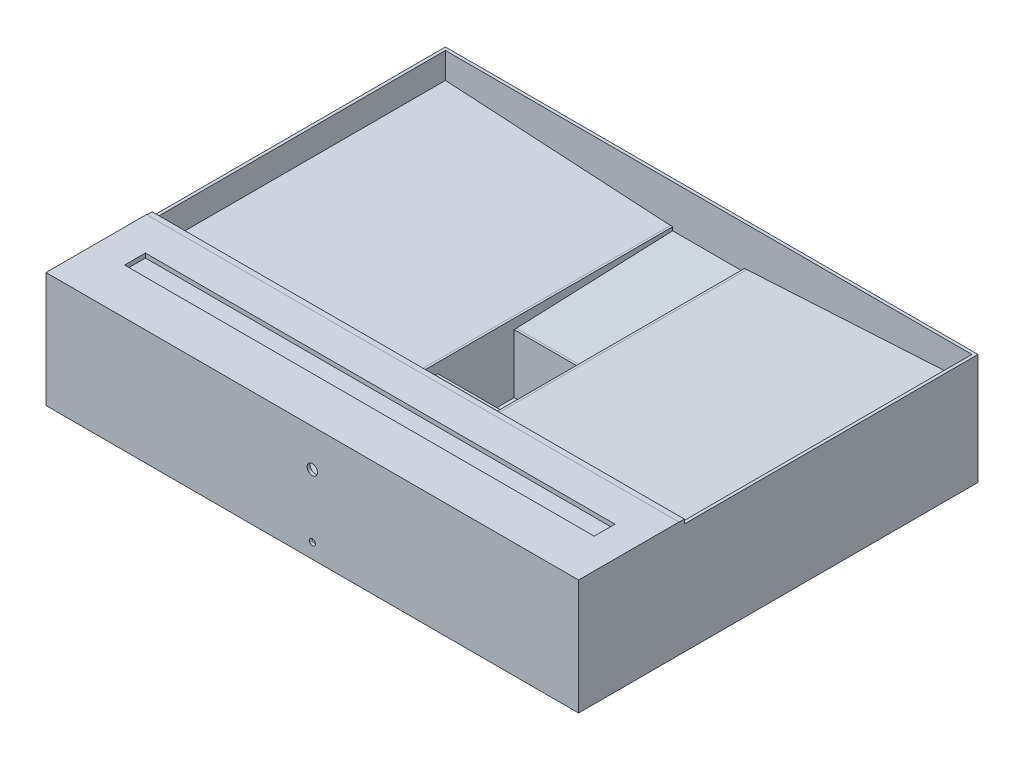
from build123d import *

# Parameters (mm, degrees)
SKETCH1_W            = 1220
SKETCH1_H            = 915
BOSS_EXTRUDE1_DEPTH  = 254
SHELL1_T             = -7
BOSS_EXTRUDE2_DEPTH  = 901
SKETCH3_W            = 175
SKETCH3_H            = 185
SKETCH3_W_2          = 165
SKETCH3_H_2          = 175
BOSS_EXTRUDE3_DEPTH  = 135
BOSS_EXTRUDE4_DEPTH  = 175
BOSS_EXTRUDE5_DEPTH  = 5
BOSS_EXTRUDE6_DEPTH  = 5
SKETCH7_W            = 1220
SKETCH7_H            = 7
BOSS_EXTRUDE7_DEPTH  = 320
SKETCH8_W            = 1348.114973262
SKETCH8_H            = 350.584679525
CUT_EXTRUDE1_DEPTH   = 8
SKETCH9_R            = 7
CUT_EXTRUDE2_DEPTH   = 10
SKETCH10_W           = 1220
SKETCH10_H           = 230
BOSS_EXTRUDE8_DEPTH  = 10
SKETCH12_W           = 1206
SKETCH12_H           = 223
BOSS_EXTRUDE10_DEPTH = 10
SKETCH14_W           = 13.994838931
SKETCH14_H           = 66.246220617
BOSS_EXTRUDE13_DEPTH = 1219.2
SKETCH15_W           = 1075.77038164
SKETCH15_H           = 47.733443392
CUT_EXTRUDE3_DEPTH   = 10
SKETCH16_R           = 11.892366701
CUT_EXTRUDE4_DEPTH   = 10


with BuildPart() as part:
    # Sketch1 → Boss-Extrude1 (new body)
    with BuildSketch(Plane(origin=(0, 0, 0), x_dir=(1, 0, 0), z_dir=(0, 1, 0))):
        Rectangle(SKETCH1_W, SKETCH1_H)
    extrude(amount=BOSS_EXTRUDE1_DEPTH)

    # Shell1
    shell1_openings = [part.faces().sort_by_distance(p)[0] for p in [
        (0, 254, 0),
    ]]
    offset(amount=SHELL1_T, openings=shell1_openings, kind=Kind.INTERSECTION)

    # Sketch2 → Boss-Extrude2 (add)
    with BuildSketch(Plane.XY.offset(-450.5)):
        Polygon((-87.5, 164.514526371), (-603, 194.514526371), (-603, 186.514526371), (-87.5, 156.514526371), align=None)
        Polygon((603, 194), (87.5, 164.514526371), (87.5, 156.514526371), (603, 186), align=None)
    extrude(amount=BOSS_EXTRUDE2_DEPTH)

    # Sketch3 → Boss-Extrude3 (add)
    with BuildSketch(Plane(origin=(0, 7, 0), x_dir=(1, 0, 0), z_dir=(0, 1, 0))):
        Rectangle(SKETCH3_W, SKETCH3_H)
        Rectangle(SKETCH3_W_2, SKETCH3_H_2, mode=Mode.SUBTRACT)
    extrude(amount=BOSS_EXTRUDE3_DEPTH)

    # Sketch4 → Boss-Extrude4 (add)
    with BuildSketch(Plane.ZY.offset(-87.5)):
        Polygon((92.5, 142), (450.5, 156.514526371), (450.5, 151.514526371), (92.5, 137), align=None)
        Polygon((-92.5, 142), (-450.5, 156.514526371), (-450.5, 151.514526371), (-92.5, 137), align=None)
    extrude(amount=BOSS_EXTRUDE4_DEPTH)

    # Sketch5 → Boss-Extrude5 (add)
    with BuildSketch(Plane(origin=(-87.5, 0, 0), x_dir=(0, 0, -1), z_dir=(1, 0, 0))):
        Polygon((450.5, 164.514526371), (450.5, 156.514526371), (92.5, 142), (-92.5, 142), (-450.5, 156.514526371), (-450.5, 164.514526371), align=None)
    extrude(amount=BOSS_EXTRUDE5_DEPTH)

    # Sketch6 → Boss-Extrude6 (add)
    with BuildSketch(Plane.ZY.offset(-87.5)):
        Polygon((450.5, 164.514526371), (450.5, 156.514526371), (92.5, 142), (-92.5, 142), (-450.5, 156.514526371), (-450.5, 164.514526371), align=None)
    extrude(amount=BOSS_EXTRUDE6_DEPTH)

    # Sketch7 → Boss-Extrude7 (add)
    with BuildSketch(Plane(origin=(0, 254, 0), x_dir=(1, 0, 0), z_dir=(0, 1, 0))):
        with Locations((0, -454)):
            Rectangle(SKETCH7_W, SKETCH7_H)
    extrude(amount=BOSS_EXTRUDE7_DEPTH)

    # Sketch8 → Cut-Extrude1 (cut, through all)
    with BuildSketch(Plane(origin=(0, 0, 450.5), x_dir=(-1, 0, 0), z_dir=(0, 0, -1))):
        with Locations((-20.633408071, 430.569613213)):
            Rectangle(SKETCH8_W, SKETCH8_H)
    extrude(amount=-CUT_EXTRUDE1_DEPTH, mode=Mode.SUBTRACT)

    # Sketch9 → Cut-Extrude2 (cut)
    with BuildSketch(Plane.XY.offset(457.5)):
        with Locations((0, 34)):
            Circle(SKETCH9_R)
    extrude(amount=-CUT_EXTRUDE2_DEPTH, mode=Mode.SUBTRACT)

    # Sketch10 → Boss-Extrude8 (add)
    with BuildSketch(Plane(origin=(0, 254, 0), x_dir=(1, 0, 0), z_dir=(0, 1, 0))):
        with Locations((0, -342.5)):
            Rectangle(SKETCH10_W, SKETCH10_H)
    extrude(amount=BOSS_EXTRUDE8_DEPTH)

    # Sketch12 → Boss-Extrude10 (add)
    with BuildSketch(Plane(origin=(0, 199, 0), x_dir=(-1, 0, 0), z_dir=(0, -1, 0))):
        with Locations((0, -339)):
            Rectangle(SKETCH12_W, SKETCH12_H)
    extrude(amount=-BOSS_EXTRUDE10_DEPTH)

    # Sketch14 → Boss-Extrude13 (add)
    with BuildSketch(Plane(origin=(610, 0, 0), x_dir=(0, 0, -1), z_dir=(1, 0, 0))):
        with Locations((-222.206337189, 230.567579207)):
            Rectangle(SKETCH14_W, SKETCH14_H)
    extrude(amount=-BOSS_EXTRUDE13_DEPTH)

    # Sketch15 → Cut-Extrude3 (cut)
    with BuildSketch(Plane(origin=(0, 264, 0), x_dir=(1, 0, 0), z_dir=(0, 1, 0))):
        with Locations((3.093834294, -328.830387814)):
            Rectangle(SKETCH15_W, SKETCH15_H)
    extrude(amount=-CUT_EXTRUDE3_DEPTH, mode=Mode.SUBTRACT)

    # Sketch16 → Cut-Extrude4 (cut)
    with BuildSketch(Plane.XY.offset(457.5)):
        with Locations((0, 177.972608665)):
            Circle(SKETCH16_R)
    extrude(amount=-CUT_EXTRUDE4_DEPTH, mode=Mode.SUBTRACT)


solid = part.part
